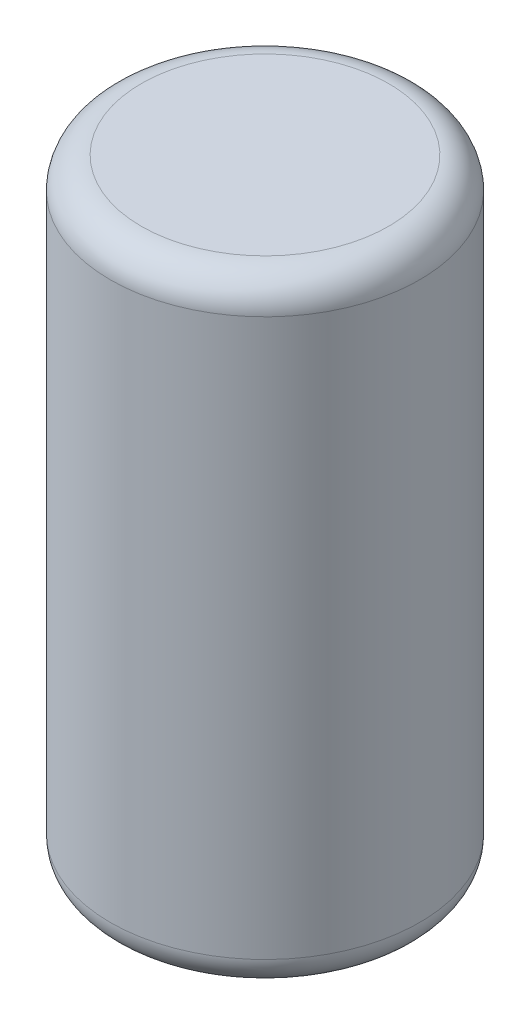
from build123d import *

# Parameters (mm, degrees)
SKETCH1_R           = 3.175
BOSS_EXTRUDE1_DEPTH = 12.7
FILLET1_R           = 0.635


with BuildPart() as part:
    # Sketch1 → Boss-Extrude1 (new body)
    with BuildSketch(Plane(origin=(0, 0, 0), x_dir=(1, 0, 0), z_dir=(0, 1, 0))):
        Circle(SKETCH1_R)
    extrude(amount=BOSS_EXTRUDE1_DEPTH)

    # Fillet1
    fillet1_edges = [part.edges().sort_by_distance(p)[0] for p in [
        (-3.175, 0, 0),
        (-3.175, 12.7, 0),
    ]]
    fillet(fillet1_edges, radius=FILLET1_R)


solid = part.part
